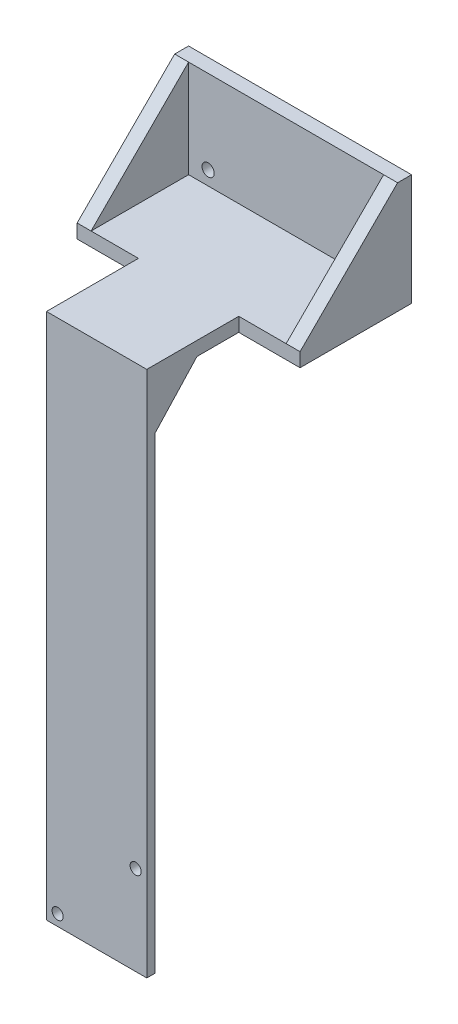
from build123d import *

# Parameters (mm, degrees)
SKETCH1_W           = 80
SKETCH1_H           = 40
BOSS_EXTRUDE1_DEPTH = 5
SKETCH2_W           = 80
SKETCH2_H           = 5
BOSS_EXTRUDE2_DEPTH = 35
BOSS_EXTRUDE3_DEPTH = 5
BOSS_EXTRUDE4_DEPTH = 5
SKETCH6_R           = 2.2
CUT_EXTRUDE2_DEPTH  = 6
SKETCH7_W           = 36
SKETCH7_H           = 5
BOSS_EXTRUDE5_DEPTH = 33
SKETCH8_W           = 36
SKETCH8_H           = 3
BOSS_EXTRUDE6_DEPTH = 184.15
BOSS_EXTRUDE7_DEPTH = 36
SKETCH10_R          = 2
CUT_EXTRUDE3_DEPTH  = 3


with BuildPart() as part:
    # Sketch1 → Boss-Extrude1 (new body)
    with BuildSketch(Plane(origin=(0, 0, 0), x_dir=(1, 0, 0), z_dir=(0, 1, 0))):
        Rectangle(SKETCH1_W, SKETCH1_H)
    extrude(amount=BOSS_EXTRUDE1_DEPTH)

    # Sketch2 → Boss-Extrude2 (add)
    with BuildSketch(Plane(origin=(0, 5, 0), x_dir=(1, 0, 0), z_dir=(0, 1, 0))):
        with Locations((0, 17.5)):
            Rectangle(SKETCH2_W, SKETCH2_H)
    extrude(amount=BOSS_EXTRUDE2_DEPTH)

    # Sketch3 → Boss-Extrude3 (add)
    with BuildSketch(Plane.ZY.offset(40)):
        Polygon((-15, 40), (20, 5), (-15, 5), align=None)
    extrude(amount=-BOSS_EXTRUDE3_DEPTH)

    # Sketch4 → Boss-Extrude4 (add)
    with BuildSketch(Plane(origin=(40, 0, 0), x_dir=(0, 0, -1), z_dir=(1, 0, 0))):
        Polygon((15, 40), (-20, 5), (15, 5), align=None)
    extrude(amount=-BOSS_EXTRUDE4_DEPTH)

    # Sketch6 → Cut-Extrude2 (cut, through all)
    with BuildSketch(Plane.XY.offset(-15)):
        with Locations((-28, 10)):
            Circle(SKETCH6_R)
        with Locations((28, 10)):
            Circle(SKETCH6_R)
    extrude(amount=-CUT_EXTRUDE2_DEPTH, mode=Mode.SUBTRACT)

    # Sketch7 → Boss-Extrude5 (add)
    with BuildSketch(Plane.XY.offset(20)):
        with Locations((0, 2.5)):
            Rectangle(SKETCH7_W, SKETCH7_H)
    extrude(amount=BOSS_EXTRUDE5_DEPTH)

    # Sketch8 → Boss-Extrude6 (add)
    with BuildSketch(Plane.XZ):
        with Locations((0, 51.5)):
            Rectangle(SKETCH8_W, SKETCH8_H)
    extrude(amount=BOSS_EXTRUDE6_DEPTH)

    # Sketch9 → Boss-Extrude7 (add)
    with BuildSketch(Plane.ZY.offset(18)):
        Polygon((35, 0), (50, -16.245521775), (50, 0), align=None)
    extrude(amount=-BOSS_EXTRUDE7_DEPTH)

    # Sketch10 → Cut-Extrude3 (cut)
    with BuildSketch(Plane.XY.offset(53)):
        with Locations((14, -152.15)):
            Circle(SKETCH10_R)
        with Locations((-14, -180.15)):
            Circle(SKETCH10_R)
    extrude(amount=-CUT_EXTRUDE3_DEPTH, mode=Mode.SUBTRACT)


solid = part.part
